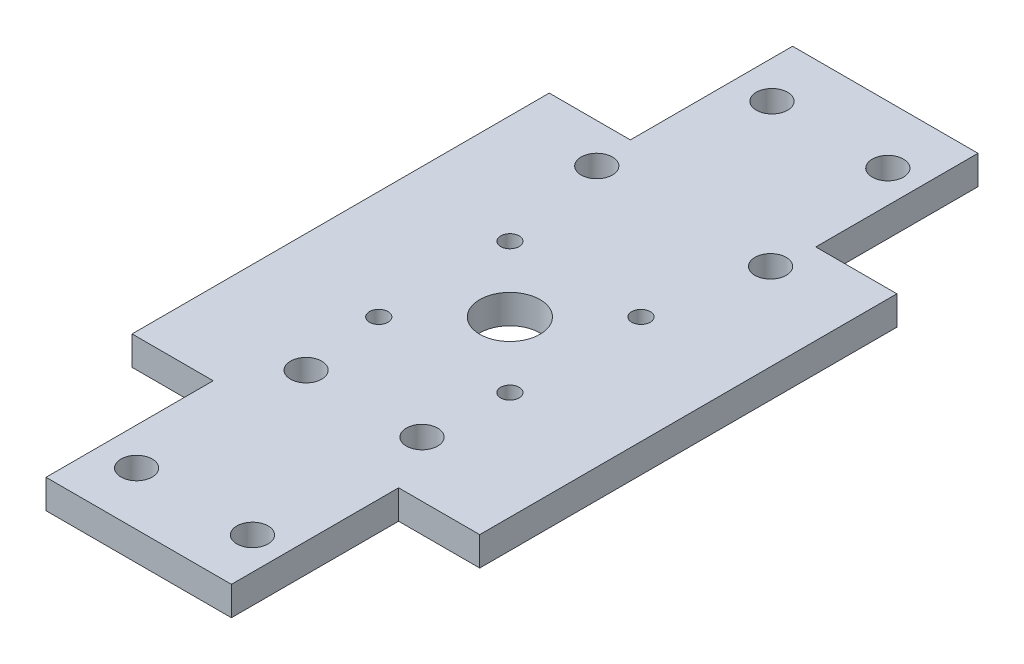
from build123d import *

# Parameters (mm, degrees)
SKETCH1_W                          = 38.1
SKETCH1_H                          = 63.5
BOSS_EXTRUDE1_DEPTH                = 3.175
SKETCH3_R                          = 3.302
SKETCH3_R_2                        = 1.016
HOLES_FOR_SERVO_MOUNT_DEPTH        = 4.175
SKETCH2_R                          = 1.7145
HOLES_FOR_TILT_SERVO_BRACKET_DEPTH = 4.175
SKETCH4_R                          = 1.7145
HOLES_FOR_PILLOW_BRACKET_DEPTH     = 4.175
SKETCH5_W                          = 8.89
SKETCH5_H                          = 17.78
CUT_EXTRUDE1_DEPTH                 = 4.175
SKETCH10_R                         = 1.7145
BOSS_EXTRUDE3_DEPTH                = 3.175


with BuildPart() as part:
    # Sketch1 → Boss-Extrude1 (new body)
    with BuildSketch(Plane(origin=(0, 0, 0), x_dir=(1, 0, 0), z_dir=(0, 1, 0))):
        Rectangle(SKETCH1_W, SKETCH1_H)
    extrude(amount=BOSS_EXTRUDE1_DEPTH)

    # Sketch3 → holes for servo mount (cut, through all)
    with BuildSketch(Plane(origin=(0, 3.175, 0), x_dir=(1, 0, 0), z_dir=(0, 1, 0))):
        with Locations((0.040685132, -9.433577206)):
            Circle(SKETCH3_R)
        with Locations((7.224890029, -16.617782103)):
            Circle(SKETCH3_R_2)
        with Locations((-7.143519765, -2.249372309)):
            Circle(SKETCH3_R_2)
        with Locations((-7.143519765, -16.617782103)):
            Circle(SKETCH3_R_2)
        with Locations((7.224890029, -2.249372309)):
            Circle(SKETCH3_R_2)
    extrude(amount=-HOLES_FOR_SERVO_MOUNT_DEPTH, mode=Mode.SUBTRACT)

    # Sketch2 → holes for tilt servo bracket (cut, through all)
    with BuildSketch(Plane(origin=(0, 3.175, 0), x_dir=(1, 0, 0), z_dir=(0, 1, 0))):
        with Locations((-6.071821378, 25.4)):
            Circle(SKETCH2_R)
        with Locations((6.628178622, 25.4)):
            Circle(SKETCH2_R)
        with Locations((6.628178622, -25.654)):
            Circle(SKETCH2_R)
        with Locations((-6.071821378, -25.654)):
            Circle(SKETCH2_R)
    extrude(amount=-HOLES_FOR_TILT_SERVO_BRACKET_DEPTH, mode=Mode.SUBTRACT)

    # Sketch4 → holes for pillow bracket (cut, through all)
    with BuildSketch(Plane(origin=(0, 3.175, 0), x_dir=(1, 0, 0), z_dir=(0, 1, 0))):
        with Locations((9.525, 9.652)):
            Circle(SKETCH4_R)
        with Locations((-9.525, 9.652)):
            Circle(SKETCH4_R)
    extrude(amount=-HOLES_FOR_PILLOW_BRACKET_DEPTH, mode=Mode.SUBTRACT)

    # Sketch5 → Cut-Extrude1 (cut, through all)
    with BuildSketch(Plane(origin=(0, 3.175, 0), x_dir=(1, 0, 0), z_dir=(0, 1, 0))):
        with Locations((-14.605, 22.86)):
            Rectangle(SKETCH5_W, SKETCH5_H)
    cut_extrude1 = extrude(amount=-CUT_EXTRUDE1_DEPTH, mode=Mode.SUBTRACT)

    # Mirror1: Cut-Extrude1 across plane
    add(cut_extrude1.mirror(Plane(origin=(0, 0, 0), x_dir=(0, 0, 1), z_dir=(1, 0, 0))), mode=Mode.SUBTRACT)

    # Sketch10 → Boss-Extrude3 (add)
    with BuildSketch(Plane(origin=(0, 3.175, 0), x_dir=(1, 0, 0), z_dir=(0, 1, 0))):
        Polygon((0, -31.75), (-10.16, -31.75), (-10.16, -50.073577206), (10.16, -50.073577206), (10.16, -31.75), align=None)
        with Locations((-6.071821378, -44.231577206)):
            Circle(SKETCH10_R, mode=Mode.SUBTRACT)
        with Locations((6.628178622, -44.231577206)):
            Circle(SKETCH10_R, mode=Mode.SUBTRACT)
    extrude(amount=-BOSS_EXTRUDE3_DEPTH)


solid = part.part
